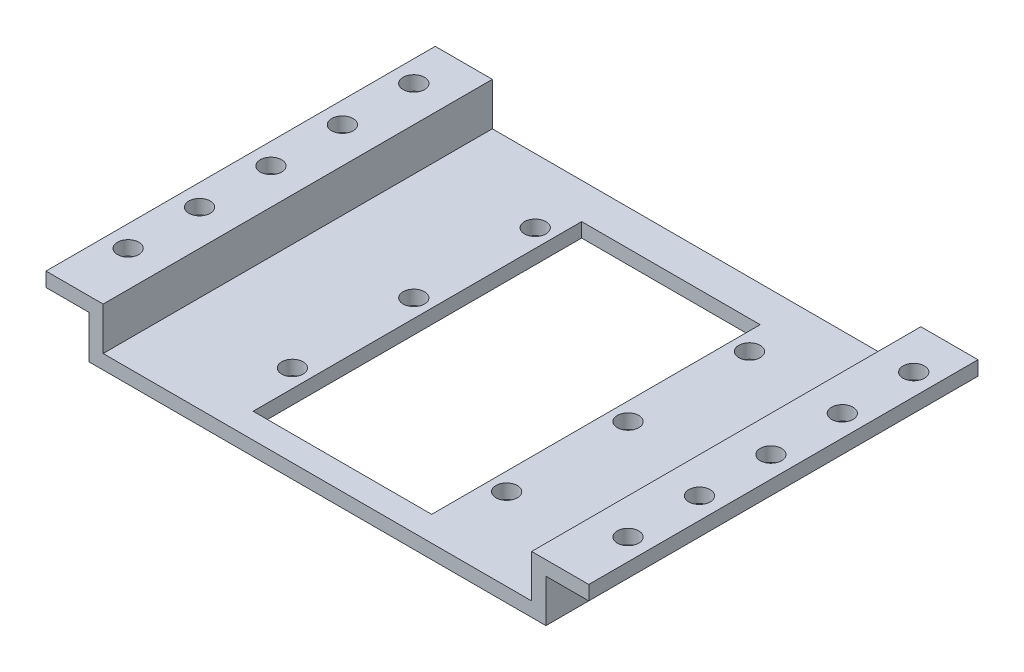
from build123d import *

# Parameters (mm, degrees)
BOSS_EXTRUDE1_DEPTH            = 50
BOSS_EXTRUDE1_2_DEPTH          = 50
SKETCH4_W                      = 1.5
SKETCH4_H                      = 2
F_3_0MM_DOWEL_HOLE1_AT_2_COUNT = 2
F_3_0MM_DOWEL_HOLE1_AT_2_PITCH = 17
F_3_0MM_DOWEL_HOLE1_AT_3_COUNT = 2
F_3_0MM_DOWEL_HOLE1_AT_3_PITCH = 34
F_3_0MM_DOWEL_HOLE1_AT_4_COUNT = 2
F_3_0MM_DOWEL_HOLE1_AT_4_PITCH = 45.343136195
F_3_0MM_DOWEL_HOLE1_AT_5_COUNT = 2
F_3_0MM_DOWEL_HOLE1_AT_5_PITCH = 34.481879299
F_3_0MM_DOWEL_HOLE1_AT_6_COUNT = 2
F_3_0MM_DOWEL_HOLE1_AT_6_PITCH = 30
SKETCH7_W                      = 1.5
SKETCH7_H                      = 8
F_3_0MM_DOWEL_HOLE2_AT_2_COUNT = 2
F_3_0MM_DOWEL_HOLE2_AT_2_PITCH = 10
F_3_0MM_DOWEL_HOLE2_AT_3_COUNT = 2
F_3_0MM_DOWEL_HOLE2_AT_3_PITCH = 10
F_3_0MM_DOWEL_HOLE2_AT_4_COUNT = 2
F_3_0MM_DOWEL_HOLE2_AT_4_PITCH = 20
SKETCH9_W                      = 25
SKETCH9_H                      = 9
BOSS_EXTRUDE3_DEPTH            = 2
MIRROR1_COPY_1_SKETCH_W        = 1.5
MIRROR1_COPY_1_SKETCH_H        = 8
MIRROR1_COPY_2_SKETCH_W        = 1.5
MIRROR1_COPY_2_SKETCH_H        = 8
MIRROR1_COPY_3_SKETCH_W        = 1.5
MIRROR1_COPY_3_SKETCH_H        = 8
SKETCH10_W                     = 76
SKETCH10_H                     = 4
CUT_EXTRUDE1_DEPTH             = 10
BOSS_EXTRUDE4_DEPTH            = 8.5
SKETCH13_W                     = 25
SKETCH13_H                     = 5
CUT_EXTRUDE2_DEPTH             = 8.5
F_3_0MM_DOWEL_HOLE3_D          = 3


with BuildPart() as part:
    # Sketch1 → Boss-Extrude1 (new body)
    with BuildSketch(Plane.XY):
        Polygon((12.5, 0), (12.5, 2), (30, 2), (30, 8), (38, 8), (38, 6), (32, 6), (32, 0), align=None)
    extrude(amount=BOSS_EXTRUDE1_DEPTH)


with BuildPart() as body_2:
    # Sketch1 → Boss-Extrude1 2 (new body)
    with BuildSketch(Plane.XY):
        Polygon((-12.5, 2), (-30, 2), (-30, 8), (-38, 8), (-38, 6), (-32, 6), (-32, 0), (-12.5, 0), align=None)
    extrude(amount=BOSS_EXTRUDE1_2_DEPTH)

    # Sketch4 → Ø3.0mm Dowel Hole1 (revolve, cut)
    with BuildSketch(Plane(origin=(-15, 2, 47), x_dir=(0, 0, 1), z_dir=(1, 0, 0))):
        with Locations((0.75, 1)):
            Rectangle(SKETCH4_W, SKETCH4_H)
    f_3_0mm_dowel_hole1 = revolve(axis=Axis((-15, 8.35, 47), (0, -1, 0)), mode=Mode.SUBTRACT)

    # Ø3.0mm Dowel Hole1 at 2: Ø3.0mm Dowel Hole1 ×2
    with Locations(*[(0, 0, -i * F_3_0MM_DOWEL_HOLE1_AT_2_PITCH) for i in range(1, F_3_0MM_DOWEL_HOLE1_AT_2_COUNT)]):
        add(f_3_0mm_dowel_hole1, mode=Mode.SUBTRACT)

    # Ø3.0mm Dowel Hole1 at 3: Ø3.0mm Dowel Hole1 ×2
    with Locations(*[(0, 0, -i * F_3_0MM_DOWEL_HOLE1_AT_3_PITCH) for i in range(1, F_3_0MM_DOWEL_HOLE1_AT_3_COUNT)]):
        add(f_3_0mm_dowel_hole1, mode=Mode.SUBTRACT)

    # Sketch7 → Ø3.0mm Dowel Hole2 (revolve, cut)
    with BuildSketch(Plane(origin=(-35, 8, 20), x_dir=(0, 0, 1), z_dir=(1, 0, 0))):
        with Locations((0.75, 4)):
            Rectangle(SKETCH7_W, SKETCH7_H)
    f_3_0mm_dowel_hole2 = revolve(axis=Axis((-35, 14.35, 20), (0, -1, 0)), mode=Mode.SUBTRACT)

    # Ø3.0mm Dowel Hole2 at 2: Ø3.0mm Dowel Hole2 ×2
    with Locations(*[(0, 0, -i * F_3_0MM_DOWEL_HOLE2_AT_2_PITCH) for i in range(1, F_3_0MM_DOWEL_HOLE2_AT_2_COUNT)]):
        add(f_3_0mm_dowel_hole2, mode=Mode.SUBTRACT)

    # Ø3.0mm Dowel Hole2 at 3: Ø3.0mm Dowel Hole2 ×2
    with Locations(*[(0, 0, i * F_3_0MM_DOWEL_HOLE2_AT_3_PITCH) for i in range(1, F_3_0MM_DOWEL_HOLE2_AT_3_COUNT)]):
        add(f_3_0mm_dowel_hole2, mode=Mode.SUBTRACT)

    # Ø3.0mm Dowel Hole2 at 4: Ø3.0mm Dowel Hole2 ×2
    with Locations(*[(0, 0, i * F_3_0MM_DOWEL_HOLE2_AT_4_PITCH) for i in range(1, F_3_0MM_DOWEL_HOLE2_AT_4_COUNT)]):
        add(f_3_0mm_dowel_hole2, mode=Mode.SUBTRACT)


with BuildPart() as part_1:
    add(part.part)

    # Ø3.0mm Dowel Hole1 at 4: Ø3.0mm Dowel Hole1 ×2
    with Locations(*[Vector(0.661621637, 0, -0.749837855) * (i * F_3_0MM_DOWEL_HOLE1_AT_4_PITCH) for i in range(1, F_3_0MM_DOWEL_HOLE1_AT_4_COUNT)]):
        add(f_3_0mm_dowel_hole1, mode=Mode.SUBTRACT)

    # Ø3.0mm Dowel Hole1 at 5: Ø3.0mm Dowel Hole1 ×2
    with Locations(*[Vector(0.870022186, 0, -0.493012572) * (i * F_3_0MM_DOWEL_HOLE1_AT_5_PITCH) for i in range(1, F_3_0MM_DOWEL_HOLE1_AT_5_COUNT)]):
        add(f_3_0mm_dowel_hole1, mode=Mode.SUBTRACT)

    # Ø3.0mm Dowel Hole1 at 6: Ø3.0mm Dowel Hole1 ×2
    with Locations(*[(i * F_3_0MM_DOWEL_HOLE1_AT_6_PITCH, 0, 0) for i in range(1, F_3_0MM_DOWEL_HOLE1_AT_6_COUNT)]):
        add(f_3_0mm_dowel_hole1, mode=Mode.SUBTRACT)

    add(body_2.part)  # Boss-Extrude3 merges body 2
    # Sketch9 → Boss-Extrude3 (add)
    with BuildSketch(Plane(origin=(0, 2, 0), x_dir=(1, 0, 0), z_dir=(0, 1, 0))):
        with Locations((0, -4.5)):
            Rectangle(SKETCH9_W, SKETCH9_H)
    extrude(amount=-BOSS_EXTRUDE3_DEPTH)

    # Mirror1: Ø3.0mm Dowel Hole2 across plane
    add(f_3_0mm_dowel_hole2.mirror(Plane(origin=(0, 0, 0), x_dir=(0, 0, 1), z_dir=(1, 0, 0))), mode=Mode.SUBTRACT)

    # Mirror1 copy 1 sketch → Mirror1 copy 1 (revolve, cut)
    with BuildSketch(Plane(origin=(35, 8, 10), x_dir=(0, 0, 1), z_dir=(-1, 0, 0))):
        with Locations((0.75, -4)):
            Rectangle(MIRROR1_COPY_1_SKETCH_W, MIRROR1_COPY_1_SKETCH_H)
    revolve(axis=Axis((35, 14.35, 10), (0, 1, 0)), mode=Mode.SUBTRACT)

    # Mirror1 copy 2 sketch → Mirror1 copy 2 (revolve, cut)
    with BuildSketch(Plane(origin=(35, 8, 30), x_dir=(0, 0, 1), z_dir=(-1, 0, 0))):
        with Locations((0.75, -4)):
            Rectangle(MIRROR1_COPY_2_SKETCH_W, MIRROR1_COPY_2_SKETCH_H)
    revolve(axis=Axis((35, 14.35, 30), (0, 1, 0)), mode=Mode.SUBTRACT)

    # Mirror1 copy 3 sketch → Mirror1 copy 3 (revolve, cut)
    with BuildSketch(Plane(origin=(35, 8, 40), x_dir=(0, 0, 1), z_dir=(-1, 0, 0))):
        with Locations((0.75, -4)):
            Rectangle(MIRROR1_COPY_3_SKETCH_W, MIRROR1_COPY_3_SKETCH_H)
    revolve(axis=Axis((35, 14.35, 40), (0, 1, 0)), mode=Mode.SUBTRACT)

    # Sketch10 → Cut-Extrude1 (cut)
    with BuildSketch(Plane(origin=(0, 8, 0), x_dir=(1, 0, 0), z_dir=(0, 1, 0))):
        with Locations((0, -2)):
            Rectangle(SKETCH10_W, SKETCH10_H)
    extrude(amount=-CUT_EXTRUDE1_DEPTH, mode=Mode.SUBTRACT)

    # Sketch12 → Boss-Extrude4 (add)
    with BuildSketch(Plane.XY.offset(50)):
        Polygon((-32, 0), (32, 0), (32, 6), (38, 6), (38, 8), (30, 8), (30, 2), (-30, 2), (-30, 8), (-38, 8), (-38, 6), (-32, 6), align=None)
    extrude(amount=BOSS_EXTRUDE4_DEPTH)

    # Sketch13 → Cut-Extrude2 (cut)
    with BuildSketch(Plane(origin=(0, 2, 0), x_dir=(1, 0, 0), z_dir=(0, 1, 0))):
        with Locations((0, -52.5)):
            Rectangle(SKETCH13_W, SKETCH13_H)
    extrude(amount=-CUT_EXTRUDE2_DEPTH, mode=Mode.SUBTRACT)

    # Ø3.0mm Dowel Hole3 (through all)
    with Locations(Plane(origin=(0, 8, 0), x_dir=(1, 0, 0), z_dir=(0, 1, 0))):
        with Locations((35, -50), (-35, -50)):
            Hole(F_3_0MM_DOWEL_HOLE3_D / 2)


solid = part_1.part
